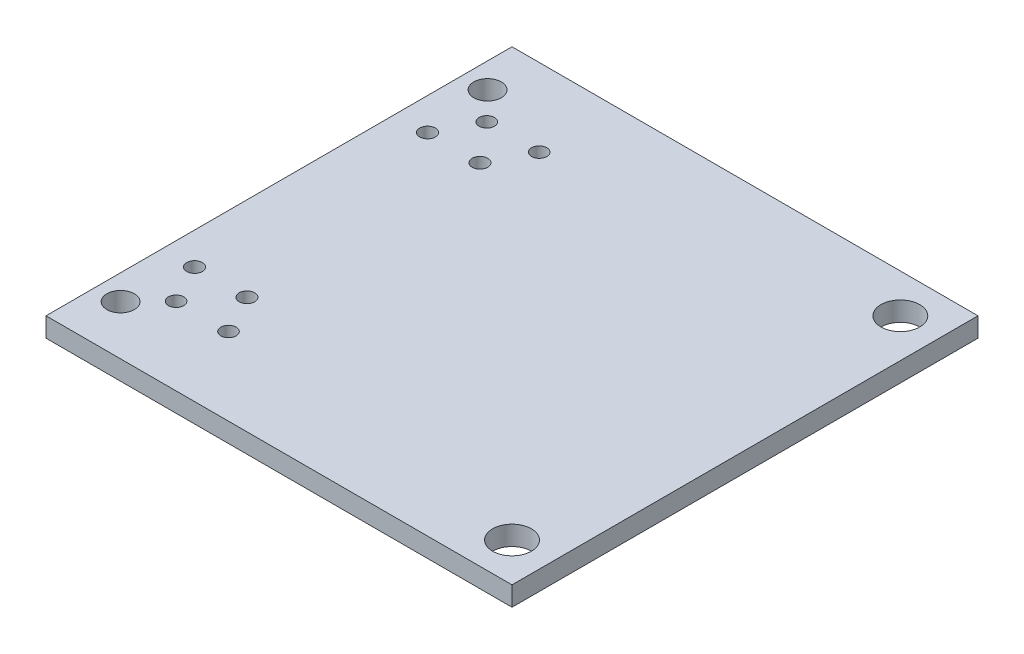
from build123d import *

# Parameters (mm, degrees)
SKETCH1_W           = 152.4
SKETCH1_H           = 152.4
SKETCH1_R           = 4.5
SKETCH1_R_2         = 2.5
SKETCH1_R_3         = 6.35
BOSS_EXTRUDE1_DEPTH = 6.35
SKETCH2_R           = 2.5527
CUT_EXTRUDE1_DEPTH  = 6.35


with BuildPart() as part:
    # Sketch1 → Boss-Extrude1 (new body)
    with BuildSketch(Plane(origin=(0, 0, 0), x_dir=(1, 0, 0), z_dir=(0, 1, 0))):
        with Locations((76.2, 76.2)):
            Rectangle(SKETCH1_W, SKETCH1_H)
        with Locations(Location((8.200009, 136.19988, 0), (0, 0, 270))):  # turned: the seam where the file's is
            Circle(SKETCH1_R, mode=Mode.SUBTRACT)
        with Locations(Location((8.200009, 16.200000112, 0), (0, 0, 270))):  # turned: the seam where the file's is
            Circle(SKETCH1_R, mode=Mode.SUBTRACT)
        with Locations(Location((17.145, 25.4, 0), (0, 0, 270))):  # turned: the seam where the file's is
            Circle(SKETCH1_R_2, mode=Mode.SUBTRACT)
        with Locations(Location((34.29, 25.4, 0), (0, 0, 270))):  # turned: the seam where the file's is
            Circle(SKETCH1_R_2, mode=Mode.SUBTRACT)
        with Locations(Location((17.145, 127, 0), (0, 0, 270))):  # turned: the seam where the file's is
            Circle(SKETCH1_R_2, mode=Mode.SUBTRACT)
        with Locations(Location((34.29, 127, 0), (0, 0, 270))):  # turned: the seam where the file's is
            Circle(SKETCH1_R_2, mode=Mode.SUBTRACT)
        with Locations(Location((139.7, 12.7, 0), (0, 0, 270))):  # turned: the seam where the file's is
            Circle(SKETCH1_R_3, mode=Mode.SUBTRACT)
        with Locations(Location((139.7, 139.7, 0), (0, 0, 270))):  # turned: the seam where the file's is
            Circle(SKETCH1_R_3, mode=Mode.SUBTRACT)
    extrude(amount=BOSS_EXTRUDE1_DEPTH)

    # Sketch2 → Cut-Extrude1 (cut)
    with BuildSketch(Plane(origin=(0, 6.35, 0), x_dir=(1, 0, 0), z_dir=(0, 1, 0))):
        with Locations(Location((10.4775, 114.3, 0), (0, 0, 270))):  # turned: the seam where the file's is
            Circle(SKETCH2_R)
        with Locations(Location((27.6225, 114.3, 0), (0, 0, 270))):  # turned: the seam where the file's is
            Circle(SKETCH2_R)
        with Locations(Location((10.4775, 38.1, 0), (0, 0, 270))):  # turned: the seam where the file's is
            Circle(SKETCH2_R)
        with Locations(Location((27.6225, 38.1, 0), (0, 0, 270))):  # turned: the seam where the file's is
            Circle(SKETCH2_R)
    extrude(amount=-CUT_EXTRUDE1_DEPTH, mode=Mode.SUBTRACT)


solid = part.part
